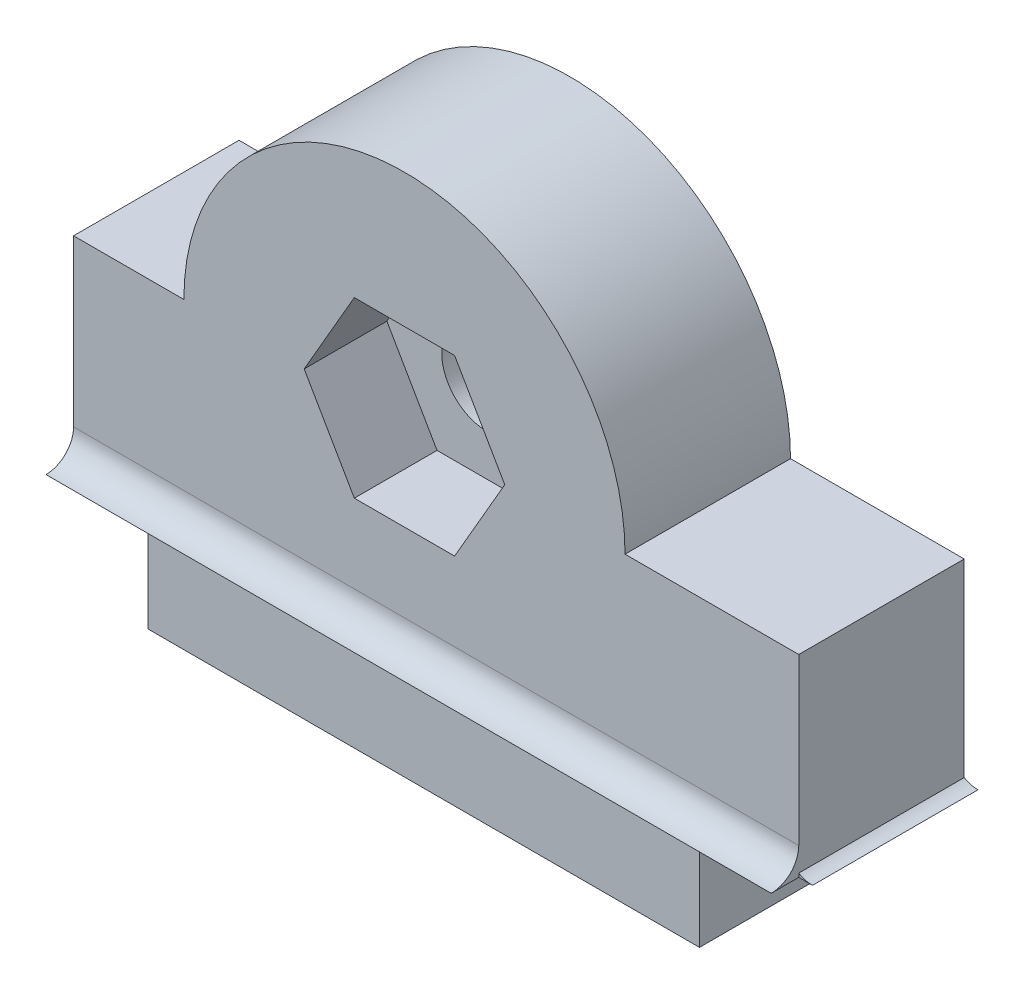
from build123d import *

# Parameters (mm, degrees)
BOSS_EXTRUDE1_DEPTH = 6
BOSS_EXTRUDE2_DEPTH = 26.3
BOSS_EXTRUDE3_DEPTH = 6
SKETCH8_R           = 1.65
BOSS_EXTRUDE4_DEPTH = 3


with BuildPart() as part:
    # Sketch1 → Boss-Extrude1 (new body)
    with BuildSketch(Plane.XY):
        with BuildLine():
            Line((0, 0), (20, 0))
            Line((20, 0), (20, 4))
            Line((20, 4), (23.6, 4))
            Line((23.6, 4), (23.6, 11))
            Line((23.6, 11), (17.3, 11))
            ThreePointArc((17.3, 11), (9.3, 19), (1.3, 11))
            Line((1.3, 11), (-2.7, 11))
            Line((-2.7, 11), (-2.7, 4))
            Line((-2.7, 4), (0, 4))
            Line((0, 4), (0, 0))
        make_face()
        Polygon((11.118653348, 14.15), (7.481346652, 14.15), (5.662693304, 11), (7.481346652, 7.85), (11.118653348, 7.85), (12.937306696, 11), align=None, mode=Mode.SUBTRACT)
    extrude(amount=BOSS_EXTRUDE1_DEPTH)

    # Sketch2 → Boss-Extrude2 (add)
    with BuildSketch(Plane.ZY.offset(2.7)):
        with BuildLine():
            Line((6, 4), (6, 5))
            ThreePointArc((6, 5), (6.292893219, 4.292893219), (7, 4))
            Line((7, 4), (6, 4))
        make_face()
    extrude(amount=-BOSS_EXTRUDE2_DEPTH)

    # Sketch4 → Boss-Extrude3 (add)
    with BuildSketch(Plane.XY.offset(6)):
        with BuildLine():
            Line((23.1, 4), (23.1, 5))
            ThreePointArc((23.1, 5), (23.392893219, 4.292893219), (24.1, 4))
            Line((24.1, 4), (23.1, 4))
        make_face()
        with BuildLine():
            Line((-1.5, 4), (-2.5, 4))
            ThreePointArc((-2.5, 4), (-1.792893219, 4.292893219), (-1.5, 5))
            Line((-1.5, 5), (-1.5, 4))
        make_face()
    extrude(amount=-BOSS_EXTRUDE3_DEPTH)

    # Sketch8 → Boss-Extrude4 (add)
    with BuildSketch(Plane.XY):
        Polygon((7.481346652, 14.15), (5.662693304, 11), (7.481346652, 7.85), (11.118653348, 7.85), (12.937306696, 11), (11.118653348, 14.15), align=None)
        with Locations((9.3, 11)):
            Circle(SKETCH8_R, mode=Mode.SUBTRACT)
    extrude(amount=BOSS_EXTRUDE4_DEPTH)


solid = part.part
